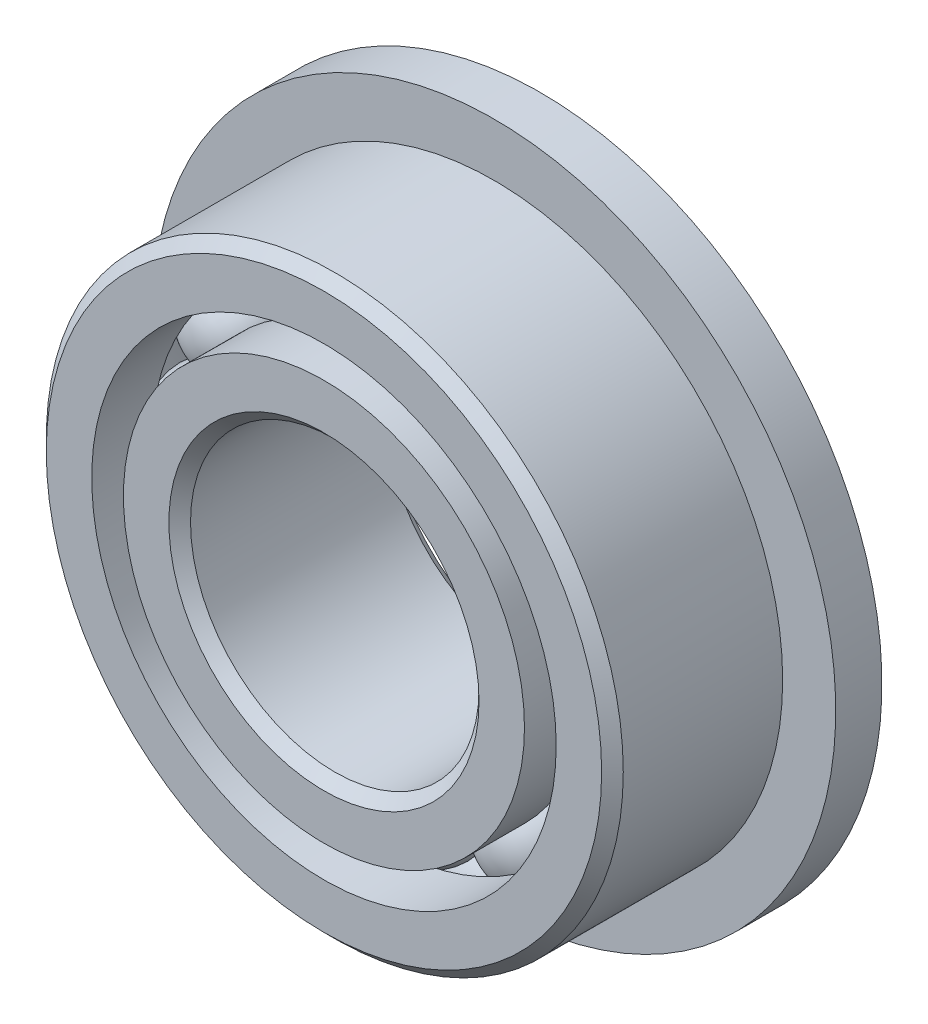
from build123d import *

# Parameters (mm, degrees)
SKETCH5_W         = 0.508
SKETCH5_H         = 0.953380975
CIRPATTERN1_COUNT = 12


with BuildPart() as part:
    # Sketch1 → Revolve1 (revolve)
    with BuildSketch(Plane(origin=(0, 0, 0), x_dir=(0, 0, -1), z_dir=(1, 0, 0))):
        with BuildLine():
            Line((1.0715625, 3.175), (-1.0715625, 3.175))
            Line((-1.0715625, 3.175), (-1.190625, 3.0559375))
            Line((-1.190625, 3.0559375), (-1.190625, 2.555700549))
            Line((-1.190625, 2.555700549), (-0.529166667, 2.555700549))
            ThreePointArc((-0.529166667, 2.555700549), (0, 2.938430721), (0.529166667, 2.555700549))
            Line((0.529166667, 2.555700549), (1.190625, 2.555700549))
            Line((1.190625, 2.555700549), (1.190625, 3.0559375))
            Line((1.190625, 3.0559375), (1.0715625, 3.175))
        make_face()
    revolve(axis=Axis((0, 0, 1.190625), (0, 0, -1)))

    # Sketch5 → Revolve5 (revolve)
    with BuildSketch(Plane(origin=(0, 0, 0), x_dir=(0, 0, -1), z_dir=(1, 0, 0))):
        with Locations((0.936625, 3.282509513)):
            Rectangle(SKETCH5_W, SKETCH5_H)
    revolve(axis=Axis((0, 0, -1.190625), (0, 0, 1)))


with BuildPart() as body_2:
    # Sketch3 → Revolve3 (revolve)
    with BuildSketch(Plane(origin=(0, 0, 0), x_dir=(0, 0, -1), z_dir=(1, 0, 0))):
        with BuildLine():
            Line((-0.529166667, 2.206799451), (-1.190625, 2.206799451))
            Line((-1.190625, 2.206799451), (-1.190625, 1.7065625))
            Line((-1.190625, 1.7065625), (-1.0715625, 1.5875))
            Line((-1.0715625, 1.5875), (1.0715625, 1.5875))
            Line((1.0715625, 1.5875), (1.190625, 1.7065625))
            Line((1.190625, 1.7065625), (1.190625, 2.206799451))
            Line((1.190625, 2.206799451), (0.529166667, 2.206799451))
            ThreePointArc((0.529166667, 2.206799451), (0, 1.824069279), (-0.529166667, 2.206799451))
        make_face()
    revolve(axis=Axis((0, 0, 1.190625), (0, 0, -1)))


with BuildPart() as body_3:
    # Sketch4 → Revolve4 (revolve)
    with BuildSketch(Plane(origin=(0, 0, 0), x_dir=(0, 0, -1), z_dir=(1, 0, 0))):
        with BuildLine():
            Line((-0.557180721, 2.38125), (0.557180721, 2.38125))
            ThreePointArc((0.557180721, 2.38125), (0, 2.938430721), (-0.557180721, 2.38125))
        make_face()
    revolve(axis=Axis((0, 2.38125, 0.557180721), (0, 0, -1)))


with BuildPart() as cirpattern1_1:
    # CirPattern1: pattern copy
    add(body_3.part.rotate(Axis((0, 0, -1.190625), (0, 0, 1)), 1 * 360 / CIRPATTERN1_COUNT))


with BuildPart() as cirpattern1_2:
    # CirPattern1: pattern copy
    add(body_3.part.rotate(Axis((0, 0, -1.190625), (0, 0, 1)), 2 * 360 / CIRPATTERN1_COUNT))


with BuildPart() as cirpattern1_3:
    # CirPattern1: pattern copy
    add(body_3.part.rotate(Axis((0, 0, -1.190625), (0, 0, 1)), 3 * 360 / CIRPATTERN1_COUNT))


with BuildPart() as cirpattern1_4:
    # CirPattern1: pattern copy
    add(body_3.part.rotate(Axis((0, 0, -1.190625), (0, 0, 1)), 4 * 360 / CIRPATTERN1_COUNT))


with BuildPart() as cirpattern1_5:
    # CirPattern1: pattern copy
    add(body_3.part.rotate(Axis((0, 0, -1.190625), (0, 0, 1)), 5 * 360 / CIRPATTERN1_COUNT))


with BuildPart() as cirpattern1_6:
    # CirPattern1: pattern copy
    add(body_3.part.rotate(Axis((0, 0, -1.190625), (0, 0, 1)), 6 * 360 / CIRPATTERN1_COUNT))


with BuildPart() as cirpattern1_7:
    # CirPattern1: pattern copy
    add(body_3.part.rotate(Axis((0, 0, -1.190625), (0, 0, 1)), 7 * 360 / CIRPATTERN1_COUNT))


with BuildPart() as cirpattern1_8:
    # CirPattern1: pattern copy
    add(body_3.part.rotate(Axis((0, 0, -1.190625), (0, 0, 1)), 8 * 360 / CIRPATTERN1_COUNT))


with BuildPart() as cirpattern1_9:
    # CirPattern1: pattern copy
    add(body_3.part.rotate(Axis((0, 0, -1.190625), (0, 0, 1)), 9 * 360 / CIRPATTERN1_COUNT))


with BuildPart() as cirpattern1_10:
    # CirPattern1: pattern copy
    add(body_3.part.rotate(Axis((0, 0, -1.190625), (0, 0, 1)), 10 * 360 / CIRPATTERN1_COUNT))


with BuildPart() as cirpattern1_11:
    # CirPattern1: pattern copy
    add(body_3.part.rotate(Axis((0, 0, -1.190625), (0, 0, 1)), 11 * 360 / CIRPATTERN1_COUNT))


solid = Compound([part.part, body_2.part, body_3.part, cirpattern1_1.part, cirpattern1_2.part, cirpattern1_3.part, cirpattern1_4.part, cirpattern1_5.part, cirpattern1_6.part, cirpattern1_7.part, cirpattern1_8.part, cirpattern1_9.part, cirpattern1_10.part, cirpattern1_11.part])
